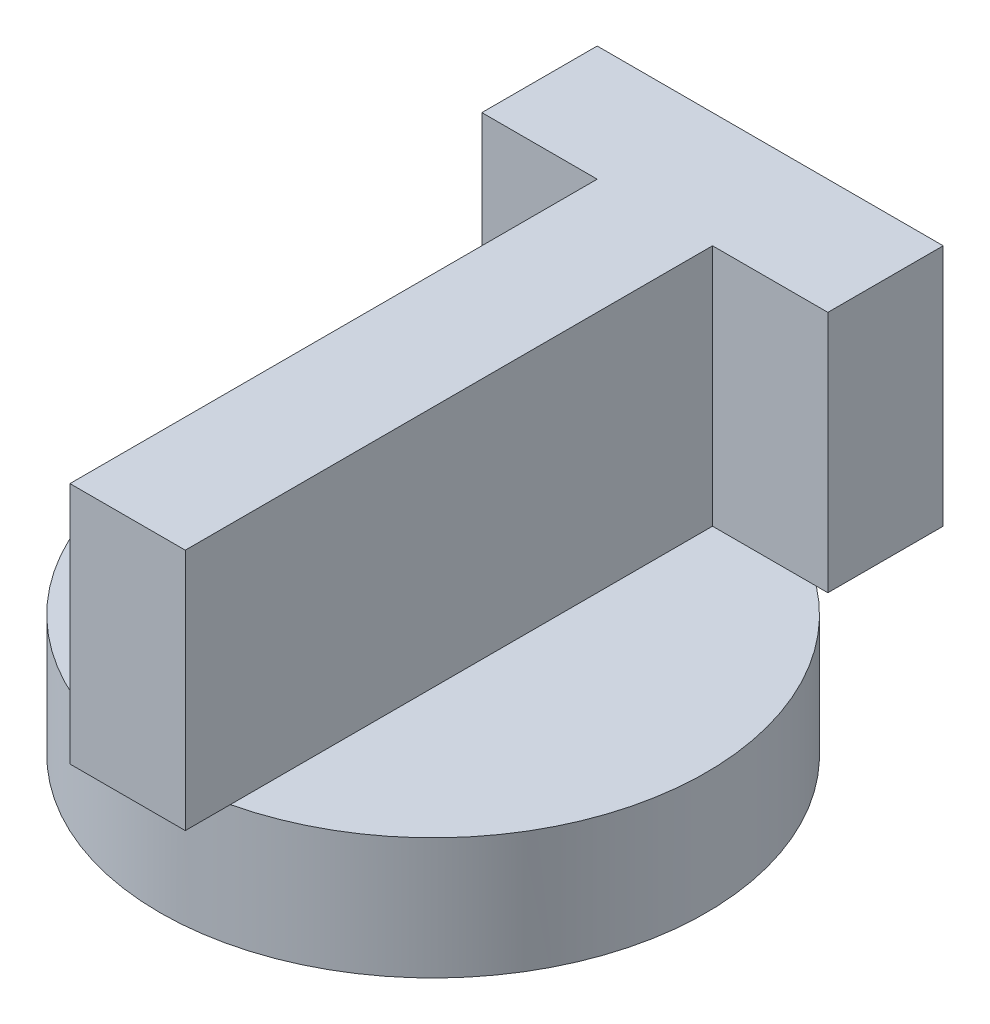
from build123d import *

# Parameters (mm, degrees)
SKETCH1_R           = 22.5
BOSS_EXTRUDE1_DEPTH = 10
BOSS_EXTRUDE2_DEPTH = 20
SKETCH3_R           = 16.5
CUT_EXTRUDE2_DEPTH  = 5


with BuildPart() as part:
    # Sketch1 → Boss-Extrude1 (new body)
    with BuildSketch(Plane(origin=(0, 0, 0), x_dir=(1, 0, 0), z_dir=(0, 1, 0))):
        with Locations(Location((0, 0, 0), (0, 0, 270))):
            Circle(SKETCH1_R)
    extrude(amount=BOSS_EXTRUDE1_DEPTH)

    # Sketch2 → Boss-Extrude2 (add)
    with BuildSketch(Plane(origin=(0, 10, 0), x_dir=(1, 0, 0), z_dir=(0, 1, 0))):
        Polygon((-13.806150904, 27.316911445), (14.687438839, 27.316911445), (14.687438839, 17.819048198), (5.189575591, 17.819048198), (5.189575591, -25.599755221), (-4.308287657, -25.599755221), (-4.308287657, 17.819048198), (-13.806150904, 17.819048198), align=None)
    extrude(amount=BOSS_EXTRUDE2_DEPTH)

    # Sketch3 → Cut-Extrude2 (cut)
    with BuildSketch(Plane.XZ):
        with BuildLine():
            ThreePointArc((-14.551420086, 2.778571429), (0, 11.5), (14.551420086, 2.778571429))
            Line((14.551420086, 2.778571429), (4.83856504, 20.948467447))
            ThreePointArc((4.83856504, 20.948467447), (0, 21.5), (-4.83856504, 20.948467447))
            Line((-4.83856504, 20.948467447), (-14.551420086, 2.778571429))
        make_face()
        with Locations((0, -5)):
            Circle(SKETCH3_R)
    extrude(amount=-CUT_EXTRUDE2_DEPTH, mode=Mode.SUBTRACT)


solid = part.part
